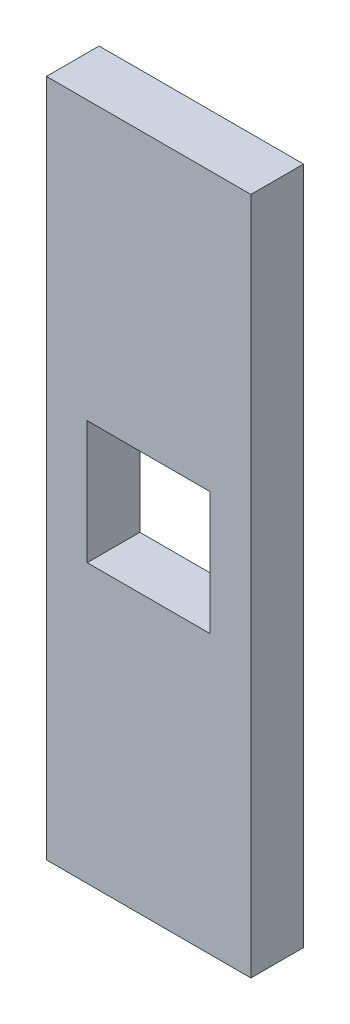
from build123d import *

# Parameters (mm, degrees)
SKETCH1_W           = 12.15
SKETCH1_H           = 12.15
BOSS_EXTRUDE1_DEPTH = 5.2


with BuildPart() as part:
    # Sketch1 → Boss-Extrude1 (new body)
    with BuildSketch(Plane.XY):
        Polygon((-0.1, 66.95), (20.1, 66.95), (20.1, 44.55), (20.1, 39.4), (20.1, 27.45), (20.1, 22.3), (20.1, -0.1), (-0.1, -0.1), (-0.1, 22.3), (-0.1, 27.45), (-0.1, 39.4), (-0.1, 44.55), align=None)
        with Locations((10, 33.425)):
            Rectangle(SKETCH1_W, SKETCH1_H, mode=Mode.SUBTRACT)
    extrude(amount=BOSS_EXTRUDE1_DEPTH)


solid = part.part
